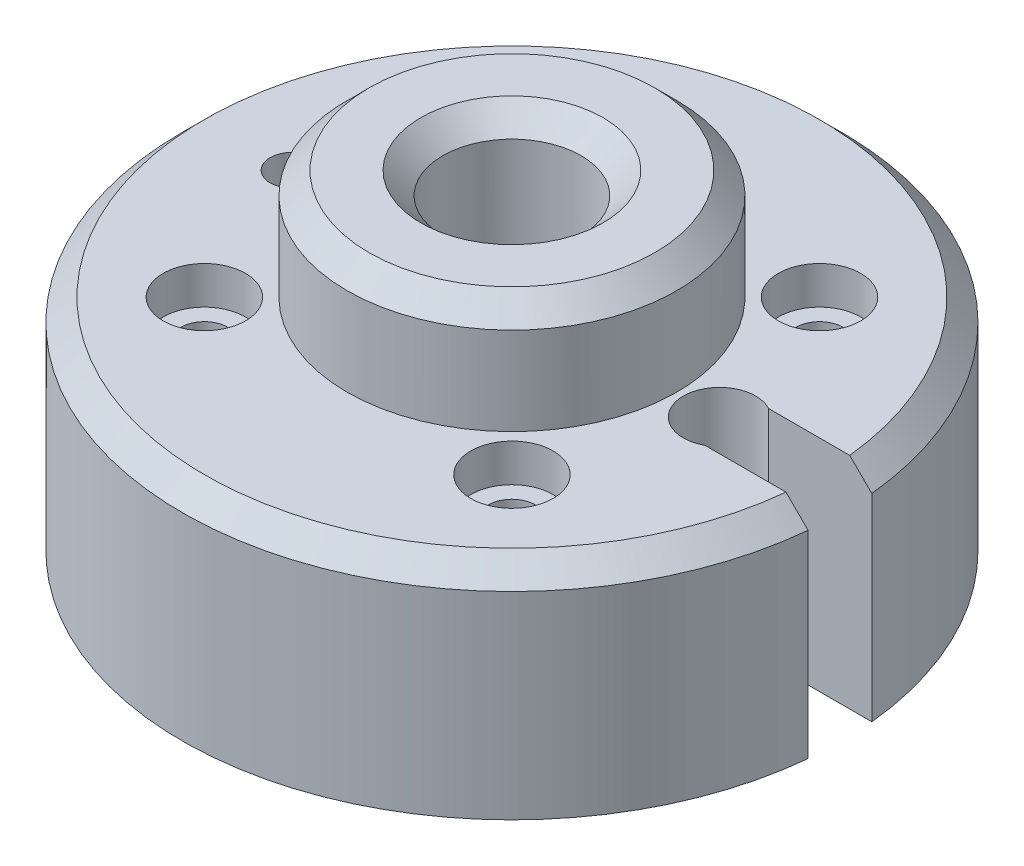
from build123d import *

# Parameters (mm, degrees)
CHAMFER1_SIZE                                  = 1.27
CBORE_FOR_2_SOCKET_HEAD_CAP_SCREW1_D           = 2.7051
CBORE_FOR_2_SOCKET_HEAD_CAP_SCREW1_DEPTH       = 12.7
CBORE_FOR_2_SOCKET_HEAD_CAP_SCREW1_CBORE_D     = 4.7625
CBORE_FOR_2_SOCKET_HEAD_CAP_SCREW1_CBORE_DEPTH = 2.1844
CUT_EXTRUDE1_DEPTH                             = 13.7
SKETCH7_R                                      = 1.27
CUT_EXTRUDE2_DEPTH                             = 13.7


with BuildPart() as part:
    # Sketch1 → Revolve1 (revolve)
    with BuildSketch(Plane.XY):
        Polygon((4, 19.05), (9.525, 19.05), (9.525, 12.7), (19.05, 12.7), (19.05, 0), (4, 0), align=None)
    revolve(axis=Axis((0, 24.600281955, 0), (0, -1, 0)))

    # Chamfer1
    chamfer1_edges = [part.edges().sort_by_distance(p)[0] for p in [
        (-19.05, 12.7, 0),
        (-9.525, 19.05, 0),
        (-4, 19.05, 0),
    ]]
    chamfer(chamfer1_edges, length=CHAMFER1_SIZE)

    # CBORE for #2 Socket Head Cap Screw1
    with Locations(Plane(origin=(0, 12.7, 0), x_dir=(1, 0, 0), z_dir=(0, 1, 0))):
        with Locations((-8.89, -8.89), (8.89, -8.89), (8.89, 8.89), (-8.89, 8.89)):
            CounterBoreHole(CBORE_FOR_2_SOCKET_HEAD_CAP_SCREW1_D / 2, CBORE_FOR_2_SOCKET_HEAD_CAP_SCREW1_CBORE_D / 2, CBORE_FOR_2_SOCKET_HEAD_CAP_SCREW1_CBORE_DEPTH, depth=CBORE_FOR_2_SOCKET_HEAD_CAP_SCREW1_DEPTH)

    # Sketch6 → Cut-Extrude1 (cut, through all)
    with BuildSketch(Plane(origin=(0, 12.7, 0), x_dir=(1, 0, 0), z_dir=(0, 1, 0))):
        with BuildLine():
            Line((12.999999, 1.8415), (18.960785262, 1.8415))
            ThreePointArc((18.960785262, 1.8415), (19.05, 0), (18.960785262, -1.8415))
            Line((18.960785262, -1.8415), (12.999999, -1.8415))
            ThreePointArc((12.999999, -1.8415), (9.9045, 0), (12.999999, 1.8415))
        make_face()
    extrude(amount=-CUT_EXTRUDE1_DEPTH, mode=Mode.SUBTRACT)

    # Sketch7 → Cut-Extrude2 (cut, through all)
    with BuildSketch(Plane(origin=(0, 12.7, 0), x_dir=(1, 0, 0), z_dir=(0, 1, 0))):
        with Locations((-12.7, 0)):
            Circle(SKETCH7_R)
    extrude(amount=-CUT_EXTRUDE2_DEPTH, mode=Mode.SUBTRACT)


solid = part.part
